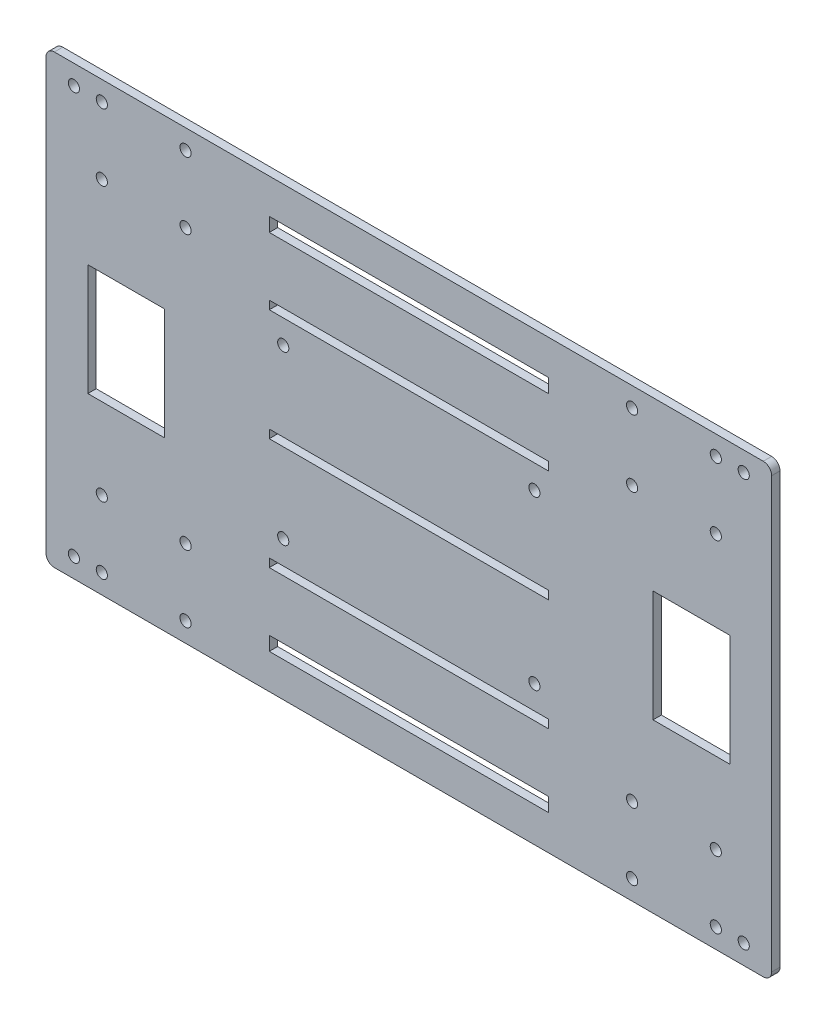
from build123d import *

# Parameters (mm, degrees)
MODEL_R             = 2
MODEL_W             = 27.5
MODEL_H             = 40
MODEL_W_2           = 100
MODEL_H_2           = 5
MODEL_H_3           = 3
EXTRUDE_1_DEPTH     = 3
SKETCH_2_R          = 2
CUT_EXTRUDE_1_DEPTH = 10


with BuildPart() as part:
    # Model → 凸台-拉伸1 (new body)
    with BuildSketch(Plane.XY):
        with BuildLine():
            Line((130, -77), (130, 77))
            ThreePointArc((130, 77), (129.121320344, 79.121320344), (127, 80))
            Line((127, 80), (-127, 80))
            ThreePointArc((-127, 80), (-129.121320344, 79.121320344), (-130, 77))
            Line((-130, 77), (-130, -77))
            ThreePointArc((-130, -77), (-129.121320344, -79.121320344), (-127, -80))
            Line((-127, -80), (127, -80))
            ThreePointArc((127, -80), (129.121320344, -79.121320344), (130, -77))
        make_face()
        with Locations((-110, 49)):
            Circle(MODEL_R, mode=Mode.SUBTRACT)
        with Locations((-80, 73)):
            Circle(MODEL_R, mode=Mode.SUBTRACT)
        with Locations((110, 73)):
            Circle(MODEL_R, mode=Mode.SUBTRACT)
        with Locations((-120, 73)):
            Circle(MODEL_R, mode=Mode.SUBTRACT)
        with Locations((80, 73)):
            Circle(MODEL_R, mode=Mode.SUBTRACT)
        with Locations((110, 49)):
            Circle(MODEL_R, mode=Mode.SUBTRACT)
        with Locations((80, -49)):
            Circle(MODEL_R, mode=Mode.SUBTRACT)
        with Locations((110, -73)):
            Circle(MODEL_R, mode=Mode.SUBTRACT)
        with Locations((-80, -73)):
            Circle(MODEL_R, mode=Mode.SUBTRACT)
        with Locations((-110, -49)):
            Circle(MODEL_R, mode=Mode.SUBTRACT)
        with Locations((-80, -49)):
            Circle(MODEL_R, mode=Mode.SUBTRACT)
        with Locations((-110, -73)):
            Circle(MODEL_R, mode=Mode.SUBTRACT)
        with Locations((80, -73)):
            Circle(MODEL_R, mode=Mode.SUBTRACT)
        with Locations((110, -49)):
            Circle(MODEL_R, mode=Mode.SUBTRACT)
        with Locations((80, 49)):
            Circle(MODEL_R, mode=Mode.SUBTRACT)
        with Locations((120, 73)):
            Circle(MODEL_R, mode=Mode.SUBTRACT)
        with Locations((120, -73)):
            Circle(MODEL_R, mode=Mode.SUBTRACT)
        with Locations((-110, 73)):
            Circle(MODEL_R, mode=Mode.SUBTRACT)
        with Locations((-80, 49)):
            Circle(MODEL_R, mode=Mode.SUBTRACT)
        with Locations((-120, -73)):
            Circle(MODEL_R, mode=Mode.SUBTRACT)
        with Locations((-101.25, 0)):
            Rectangle(MODEL_W, MODEL_H, mode=Mode.SUBTRACT)
        with Locations((101.25, 0)):
            Rectangle(MODEL_W, MODEL_H, mode=Mode.SUBTRACT)
        with Locations((0, -65)):
            Rectangle(MODEL_W_2, MODEL_H_2, mode=Mode.SUBTRACT)
        with Locations((0, 65)):
            Rectangle(MODEL_W_2, MODEL_H_2, mode=Mode.SUBTRACT)
        Rectangle(MODEL_W_2, MODEL_H_3, mode=Mode.SUBTRACT)
        with Locations((0, -40)):
            Rectangle(MODEL_W_2, MODEL_H_3, mode=Mode.SUBTRACT)
        with Locations((0, 40)):
            Rectangle(MODEL_W_2, MODEL_H_3, mode=Mode.SUBTRACT)
    extrude(amount=EXTRUDE_1_DEPTH)

    # 草图2 → 切除-拉伸1 (cut)
    with BuildSketch(Plane.XY.offset(3)):
        with Locations((-45, 30)):
            Circle(SKETCH_2_R)
        with Locations((45, 30)):
            Circle(SKETCH_2_R)
        with Locations((45, -30)):
            Circle(SKETCH_2_R)
        with Locations((-45, -30)):
            Circle(SKETCH_2_R)
    extrude(amount=-CUT_EXTRUDE_1_DEPTH, mode=Mode.SUBTRACT)


solid = part.part
